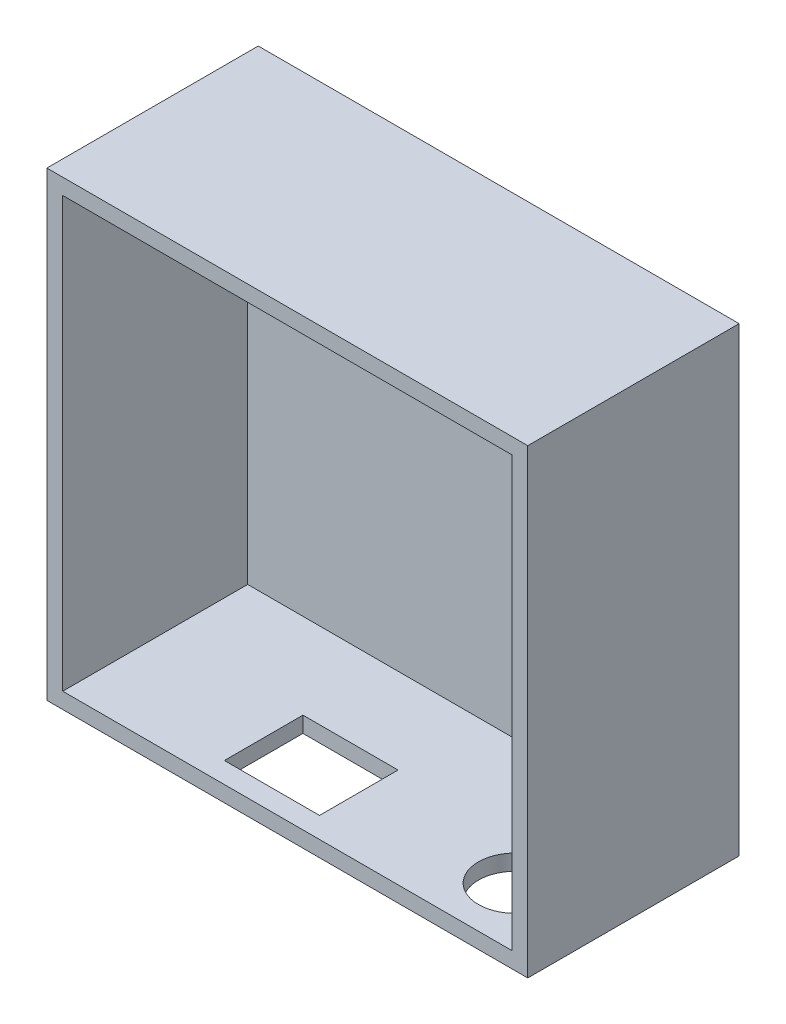
from build123d import *

# Parameters (mm, degrees)
SKETCH3_W                = 91
SKETCH3_H                = 87.244293111
BOSS_EXTRUDE1_DEPTH      = 35
BOSS_EXTRUDE1_DEPTH_BACK = 5
SKETCH2_W                = 85
SKETCH2_H                = 81.244293111
CUT_EXTRUDE1_DEPTH       = 41
CUT_EXTRUDE2_REACH       = 89.244
SKETCH5_R                = 7
SKETCH5_W                = 18
SKETCH5_H                = 14.87


with BuildPart() as part:
    # Sketch3 → Boss-Extrude1 (new body, two sides)
    with BuildSketch(Plane.XY) as boss_extrude1_sk:
        with Locations((40.316463084, 38.577850393)):
            Rectangle(SKETCH3_W, SKETCH3_H)
    extrude(amount=BOSS_EXTRUDE1_DEPTH)
    extrude(boss_extrude1_sk.sketch, amount=-BOSS_EXTRUDE1_DEPTH_BACK)

    # Sketch2 → Cut-Extrude1 (cut)
    with BuildSketch(Plane.XY):
        with Locations((40.316463084, 38.577850393)):
            Rectangle(SKETCH2_W, SKETCH2_H)
    extrude(amount=CUT_EXTRUDE1_DEPTH, mode=Mode.SUBTRACT)

    # Sketch5 → Cut-Extrude2 (cut, up to next)
    with BuildSketch(Plane.XZ.offset(5.044296163), mode=Mode.PRIVATE) as cut_extrude2_sk1:
        with Locations((72.107645341, 23.62352)):
            Circle(SKETCH5_R)
    cut_extrude2_tool1 = extrude(cut_extrude2_sk1.sketch, amount=-CUT_EXTRUDE2_REACH, mode=Mode.PRIVATE) & part.part
    add(cut_extrude2_tool1.solids().sort_by_distance((72.107645, -5.044296, 23.62352))[0], mode=Mode.SUBTRACT)
    # Sketch5 → Cut-Extrude2 (cut, up to next)
    with BuildSketch(Plane.XZ.offset(5.044296163), mode=Mode.PRIVATE) as cut_extrude2_sk2:
        with Locations((33.464005425, 23.62352)):
            Rectangle(SKETCH5_W, SKETCH5_H)
    cut_extrude2_tool2 = extrude(cut_extrude2_sk2.sketch, amount=-CUT_EXTRUDE2_REACH, mode=Mode.PRIVATE) & part.part
    add(cut_extrude2_tool2.solids().sort_by_distance((33.464005, -5.044296, 23.62352))[0], mode=Mode.SUBTRACT)


solid = part.part
